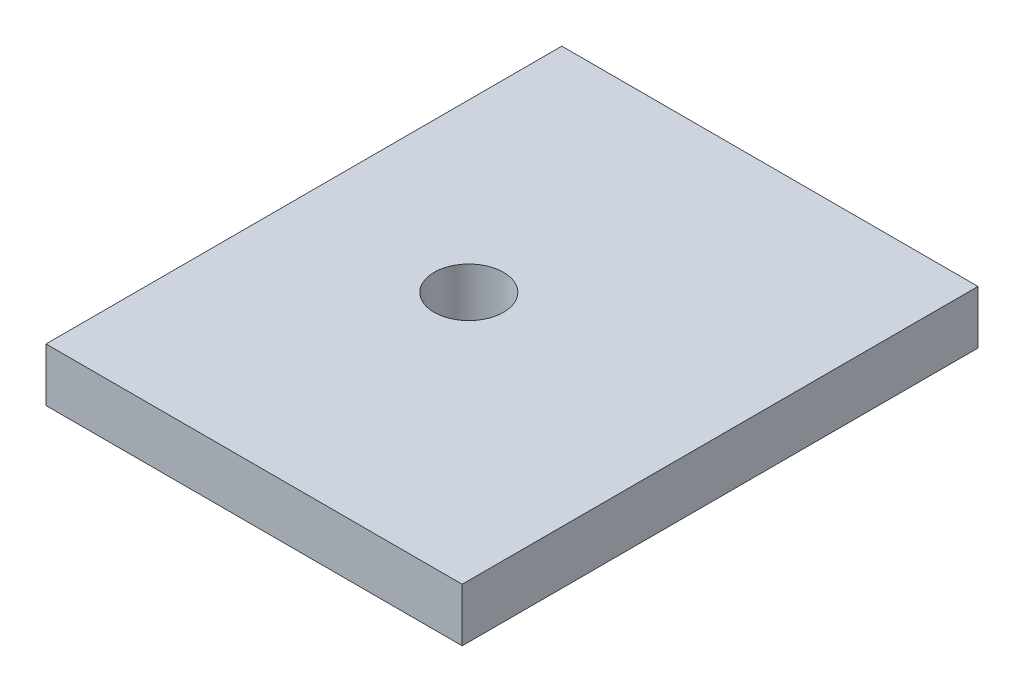
from build123d import *

# Parameters (mm, degrees)
BOSS_EXTRUDE1_DEPTH   = 3
BOSS_EXTRUDE1_2_DEPTH = 3
SKETCH1_W             = 23.4
SKETCH1_H             = 29
SKETCH1_R             = 1
BOSS_EXTRUDE1_3_DEPTH = 3
FILLET1_R             = 2
SKETCH5_R             = 1.44
CUT_EXTRUDE3_DEPTH    = 10
CUT_EXTRUDE4_DEPTH    = 10
SKETCH8_R             = 1
CUT_EXTRUDE5_DEPTH    = 10
SKETCH9_R             = 3.026992654
BOSS_EXTRUDE3_DEPTH   = 3
SKETCH10_R            = 1.95
CUT_EXTRUDE6_DEPTH    = 10
SKETCH13_W            = 23.4
SKETCH13_H            = 29
SKETCH13_R            = 1.95
BOSS_EXTRUDE4_DEPTH   = 3


with BuildPart() as part:
    # Sketch1 → Boss-Extrude1 (new body)
    with BuildSketch(Plane(origin=(0, 0, 0), x_dir=(1, 0, 0), z_dir=(0, 1, 0))):
        with BuildLine():
            add(Edge.make_bspline(
                [(19.180993887, -14.242526212), (19.80083761, -12.341053413), (17.899318471, -11.721194585), (17.279474749, -13.622667384), (16.659631026, -15.524140184), (18.561150164, -16.143999012), (19.180993887, -14.242526212)],
                knots=[0, 0, 0, 0, 0.5, 0.5, 0.5, 1, 1, 1, 1], degree=3, weights=[1, 0.333333333, 0.333333333, 1, 0.333333333, 0.333333333, 1]))
        make_face()
    extrude(amount=BOSS_EXTRUDE1_DEPTH)


with BuildPart() as body_2:
    # Sketch1 → Boss-Extrude1 2 (new body)
    with BuildSketch(Plane(origin=(0, 0, 0), x_dir=(1, 0, 0), z_dir=(0, 1, 0))):
        with BuildLine():
            add(Edge.make_bspline(
                [(22.488505608, -4.096188772), (23.108349331, -2.194715972), (21.206830193, -1.574857144), (20.58698647, -3.476329943), (19.967142747, -5.377802743), (21.868661885, -5.997661571), (22.488505608, -4.096188772)],
                knots=[0, 0, 0, 0, 0.5, 0.5, 0.5, 1, 1, 1, 1], degree=3, weights=[1, 0.333333333, 0.333333333, 1, 0.333333333, 0.333333333, 1]))
        make_face()
    extrude(amount=BOSS_EXTRUDE1_2_DEPTH)


with BuildPart() as body_3:
    # Sketch1 → Boss-Extrude1 3 (new body)
    with BuildSketch(Plane(origin=(0, 0, 0), x_dir=(1, 0, 0), z_dir=(0, 1, 0))):
        Rectangle(SKETCH1_W, SKETCH1_H)
        with Locations(Location((9, 8.9, 0), (0, 0, 270))):
            Circle(SKETCH1_R, mode=Mode.SUBTRACT)
        with Locations(Location((9, -8.5, 0), (0, 0, 90))):
            Circle(SKETCH1_R, mode=Mode.SUBTRACT)
        with Locations(Location((-9, -8.5, 0), (0, 0, 90))):
            Circle(SKETCH1_R, mode=Mode.SUBTRACT)
        with Locations(Location((1.7, -8.5, 0), (0, 0, 90))):
            Circle(SKETCH1_R, mode=Mode.SUBTRACT)
    extrude(amount=BOSS_EXTRUDE1_3_DEPTH)

    # Fillet1
    fillet1_edges = [body_3.edges().sort_by_distance(p)[0] for p in [
        (11.7, 1.5, 14.5),
        (-11.7, 1.5, 14.5),
        (-11.7, 1.5, -14.5),
        (11.7, 1.5, -14.5),
    ]]
    fillet(fillet1_edges, radius=FILLET1_R)

    # Sketch5 → Cut-Extrude3 (cut)
    with BuildSketch(Plane.XZ):
        with Locations(Location((-2.145634177, 3.61037734, 0), (0, 0, 270))):
            Circle(SKETCH5_R)
    extrude(amount=-CUT_EXTRUDE3_DEPTH, mode=Mode.SUBTRACT)

    # Sketch8 → Cut-Extrude5 (cut)
    with BuildSketch(Plane(origin=(0, 3, 0), x_dir=(1, 0, 0), z_dir=(0, 1, 0))):
        with Locations(Location((1.7, 8.9, 0), (0, 0, 270))):
            Circle(SKETCH8_R)
        with Locations(Location((-9, 8.9, 0), (0, 0, 270))):
            Circle(SKETCH8_R)
    extrude(amount=-CUT_EXTRUDE5_DEPTH, mode=Mode.SUBTRACT)

    # Sketch9 → Boss-Extrude3 (add)
    with BuildSketch(Plane(origin=(0, 3, 0), x_dir=(1, 0, 0), z_dir=(0, 1, 0))):
        with Locations((-2.145634177, -3.61037734)):
            Circle(SKETCH9_R)
    extrude(amount=-BOSS_EXTRUDE3_DEPTH)

    # Sketch10 → Cut-Extrude6 (cut)
    with BuildSketch(Plane(origin=(0, 3, 0), x_dir=(1, 0, 0), z_dir=(0, 1, 0))):
        with Locations(Location((-2.328177417, -0.1, 0), (0, 0, 270))):
            Circle(SKETCH10_R)
    extrude(amount=-CUT_EXTRUDE6_DEPTH, mode=Mode.SUBTRACT)

    # Sketch13 → Boss-Extrude4 (add)
    with BuildSketch(Plane(origin=(0, 3, 0), x_dir=(1, 0, 0), z_dir=(0, 1, 0))):
        Rectangle(SKETCH13_W, SKETCH13_H)
        with Locations(Location((-2.328177417, -0.1, 0), (0, 0, 270))):
            Circle(SKETCH13_R, mode=Mode.SUBTRACT)
    extrude(amount=-BOSS_EXTRUDE4_DEPTH)


with BuildPart() as cut_extrude4_tool:
    # Sketch7 → Cut-Extrude4 (new body)
    with BuildSketch(Plane(origin=(0, 3, 0), x_dir=(1, 0, 0), z_dir=(0, 1, 0))):
        with BuildLine():
            add(Edge.make_bspline(
                [(19.180993887, -14.242526212), (19.80083761, -12.341053413), (17.899318471, -11.721194585), (17.279474749, -13.622667384), (16.659631026, -15.524140184), (18.561150164, -16.143999012), (19.180993887, -14.242526212)],
                knots=[0, 0, 0, 0, 0.5, 0.5, 0.5, 1, 1, 1, 1], degree=3, weights=[1, 0.333333333, 0.333333333, 1, 0.333333333, 0.333333333, 1]))
        make_face()
        with BuildLine():
            add(Edge.make_bspline(
                [(22.488505608, -4.096188772), (23.108349331, -2.194715972), (21.206830193, -1.574857144), (20.58698647, -3.476329943), (19.967142747, -5.377802743), (21.868661885, -5.997661571), (22.488505608, -4.096188772)],
                knots=[0, 0, 0, 0, 0.5, 0.5, 0.5, 1, 1, 1, 1], degree=3, weights=[1, 0.333333333, 0.333333333, 1, 0.333333333, 0.333333333, 1]))
        make_face()
    extrude(amount=-CUT_EXTRUDE4_DEPTH)


with BuildPart() as part_1:
    add(part.part)

    # Cut-Extrude4: cut by cut_extrude4_tool
    add(cut_extrude4_tool.part, mode=Mode.SUBTRACT)


with BuildPart() as body_2_1:
    add(body_2.part)

    # Cut-Extrude4: cut by cut_extrude4_tool
    add(cut_extrude4_tool.part, mode=Mode.SUBTRACT)


solid = body_3.part
